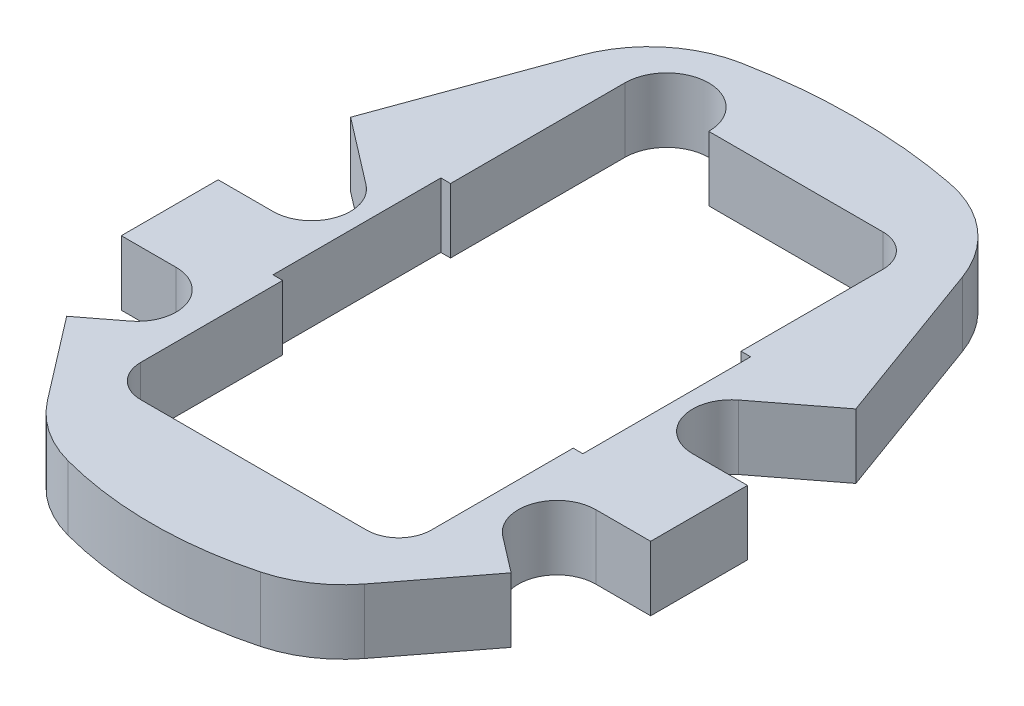
from build123d import *

# Parameters (mm, degrees)
EXTRUSION1_DEPTH = 10
EXTRUSION3_DEPTH = 10


with BuildPart() as part:
    # Esquisse1 → Extrusion1 (new body)
    with BuildSketch(Plane(origin=(0, 0, 0), x_dir=(1, 0, 0), z_dir=(0, 1, 0))):
        with BuildLine():
            Line((29.668404138, 42.162758726), (41, 11.029454967))
            Line((41, 11.029454967), (41, -23.970545033))
            Line((41, -23.970545033), (24.563441417, -45.391085221))
            ThreePointArc((24.563441417, -45.391085221), (20.269848943, -49.408841824), (14.910467873, -51.828415958))
            ThreePointArc((14.910467873, -51.828415958), (0, -53.777742922), (-14.910467873, -51.828415958))
            ThreePointArc((-14.910467873, -51.828415958), (-20.269848943, -49.408841824), (-24.563441417, -45.391085221))
            Line((-24.563441417, -45.391085221), (-41, -23.970545033))
            Line((-41, -23.970545033), (-41, 11.029454967))
            Line((-41, 11.029454967), (-29.668404138, 42.162758726))
            ThreePointArc((-29.668404138, 42.162758726), (-24.431019103, 49.704781186), (-16.15498682, 53.682166564))
            ThreePointArc((-16.15498682, 53.682166564), (0, 55.222257078), (16.15498682, 53.682166564))
            ThreePointArc((16.15498682, 53.682166564), (24.431019103, 49.704781186), (29.668404138, 42.162758726))
        make_face()
        with BuildLine():
            Line((-22.5, -11), (-22.5, -33))
            ThreePointArc((-22.5, -33), (-21.035533906, -36.535533906), (-17.5, -38))
            Line((-17.5, -38), (17.5, -38))
            ThreePointArc((17.5, -38), (21.035533906, -36.535533906), (22.5, -33))
            Line((22.5, -33), (22.5, -11))
            Line((22.5, -11), (24, -11))
            Line((24, -11), (24, 15))
            Line((24, 15), (22.5, 15))
            Line((22.5, 15), (22.5, 37))
            ThreePointArc((22.5, 37), (21.035533906, 40.535533906), (17.5, 42))
            Line((17.5, 42), (-9.5, 42))
            ThreePointArc((-9.5, 42), (-16, 48.5), (-22.5, 42))
            Line((-22.5, 42), (-22.5, 15))
            Line((-22.5, 15), (-24, 15))
            Line((-24, 15), (-24, -11))
            Line((-24, -11), (-22.5, -11))
        make_face(mode=Mode.SUBTRACT)
    extrude(amount=EXTRUSION1_DEPTH)

    # Esquisse2 → Extrusion3 (cut)
    with BuildSketch(Plane(origin=(0, 10, 0), x_dir=(-1, 0, 0), z_dir=(0, 1, 0))):
        with BuildLine():
            Line((-44.290652496, 17.5), (-32.5, 17.5))
            ThreePointArc((-32.5, 17.5), (-26.818419223, 21.571363208), (-28.847431426, 28.260120042))
            Line((-28.847431426, 28.260120042), (-39.653910261, 36.552222897))
            Line((-39.653910261, 36.552222897), (-44.290652496, 29.7455314))
            Line((-44.290652496, 29.7455314), (-44.290652496, 17.5))
        make_face()
        with BuildLine():
            Line((-44.290652496, -9.7455314), (-44.290652496, 2.5))
            Line((-44.290652496, 2.5), (-32.5, 2.5))
            ThreePointArc((-32.5, 2.5), (-26.818419223, -1.571363208), (-28.847431426, -8.260120042))
            Line((-28.847431426, -8.260120042), (-39.653910261, -16.552222897))
            Line((-39.653910261, -16.552222897), (-44.290652496, -9.7455314))
        make_face()
        with BuildLine():
            Line((44.290652496, 2.5), (32.5, 2.5))
            ThreePointArc((32.5, 2.5), (26.818419223, -1.571363208), (28.847431426, -8.260120042))
            Line((28.847431426, -8.260120042), (39.653910261, -16.552222897))
            Line((39.653910261, -16.552222897), (44.290652496, -9.7455314))
            Line((44.290652496, -9.7455314), (44.290652496, 2.5))
        make_face()
        with BuildLine():
            Line((44.290652496, 29.7455314), (44.290652496, 17.5))
            Line((44.290652496, 17.5), (32.5, 17.5))
            ThreePointArc((32.5, 17.5), (26.818419223, 21.571363208), (28.847431426, 28.260120042))
            Line((28.847431426, 28.260120042), (39.653910261, 36.552222897))
            Line((39.653910261, 36.552222897), (44.290652496, 29.7455314))
        make_face()
    extrude(amount=-EXTRUSION3_DEPTH, mode=Mode.SUBTRACT)


solid = part.part
